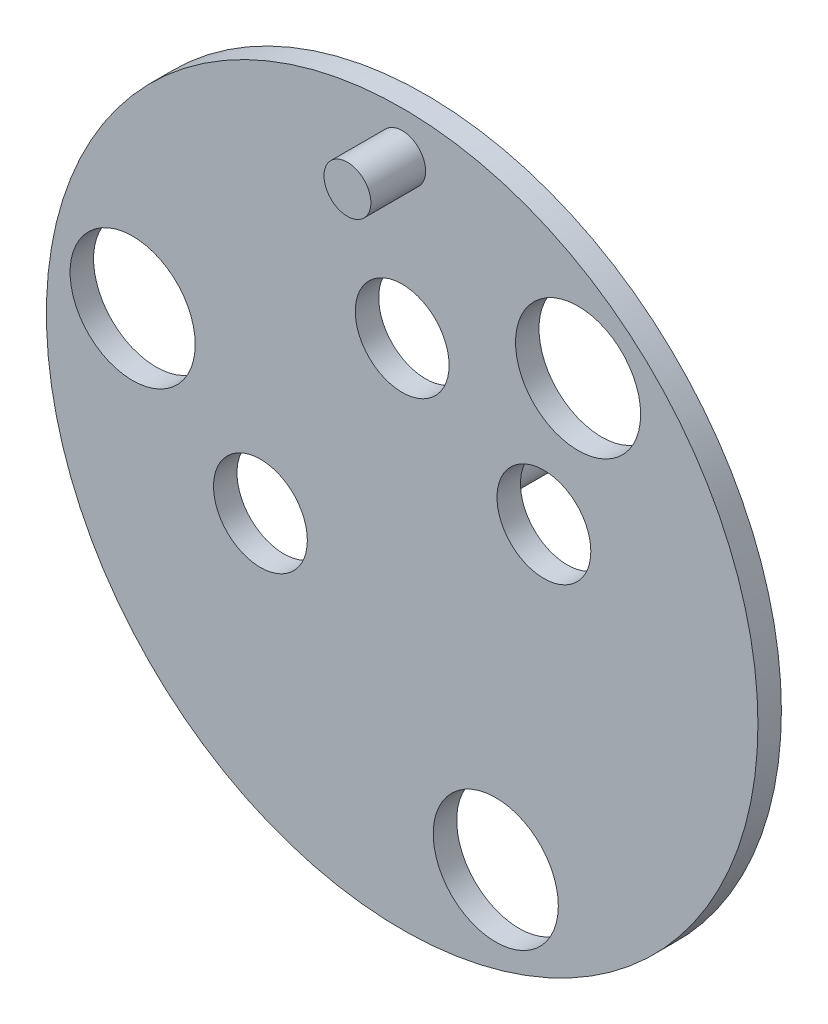
from build123d import *

# Parameters (mm, degrees)
SKETCH1_R           = 227.5
BOSS_EXTRUDE1_DEPTH = 7.5
BOSS_EXTRUDE2_START = 7.5
SKETCH1_3_R         = 15
BOSS_EXTRUDE2_DEPTH = 35
SKETCH2_R           = 40
SKETCH2_R_2         = 30
CUT_EXTRUDE1_DEPTH  = 16
BOSS_EXTRUDE3_START = -7.5
SKETCH3_R           = 15
BOSS_EXTRUDE3_DEPTH = 74.827954589


with BuildPart() as part:
    # Sketch1 → Boss-Extrude1 (new body, symmetric)
    with BuildSketch(Plane.XY):
        Circle(SKETCH1_R)
    extrude(amount=BOSS_EXTRUDE1_DEPTH, both=True)

    # Sketch1_3 → Boss-Extrude2 (add)
    with BuildSketch(Plane.XY.offset(BOSS_EXTRUDE2_START)):
        with Locations((0, 200)):
            Circle(SKETCH1_3_R)
    extrude(amount=BOSS_EXTRUDE2_DEPTH)

    # Sketch2 → Cut-Extrude1 (cut, through all)
    with BuildSketch(Plane.XY.offset(7.5)):
        with Locations((-172.341356777, 30.388431092)):
            Circle(SKETCH2_R)
        with Locations((0, 100)):
            Circle(SKETCH2_R_2)
        with Locations((90.630778704, 42.261826174)):
            Circle(SKETCH2_R_2)
        with Locations((-90.630778704, -42.261826174)):
            Circle(SKETCH2_R_2)
        with Locations((112.487831695, 134.057777546)):
            Circle(SKETCH2_R)
        with Locations((59.853525082, -164.446208638)):
            Circle(SKETCH2_R)
    extrude(amount=-CUT_EXTRUDE1_DEPTH, mode=Mode.SUBTRACT)

    # Sketch3 → Boss-Extrude3 (add)
    with BuildSketch(Plane.XY.offset(BOSS_EXTRUDE3_START)):
        Circle(SKETCH3_R)
    extrude(amount=-BOSS_EXTRUDE3_DEPTH)


solid = part.part
